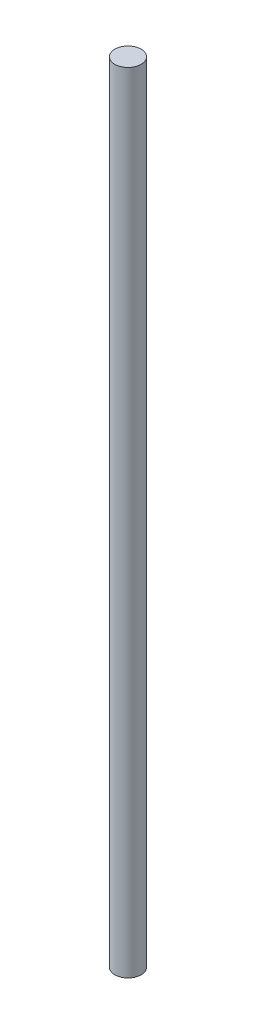
from build123d import *

# Parameters (mm, degrees)
SKETCH1_R           = 2.5
BOSS_EXTRUDE1_DEPTH = 150


with BuildPart() as part:
    # Sketch1 → Boss-Extrude1 (new body)
    with BuildSketch(Plane(origin=(0, 0, 0), x_dir=(1, 0, 0), z_dir=(0, 1, 0))):
        Circle(SKETCH1_R)
    extrude(amount=BOSS_EXTRUDE1_DEPTH)


solid = part.part
